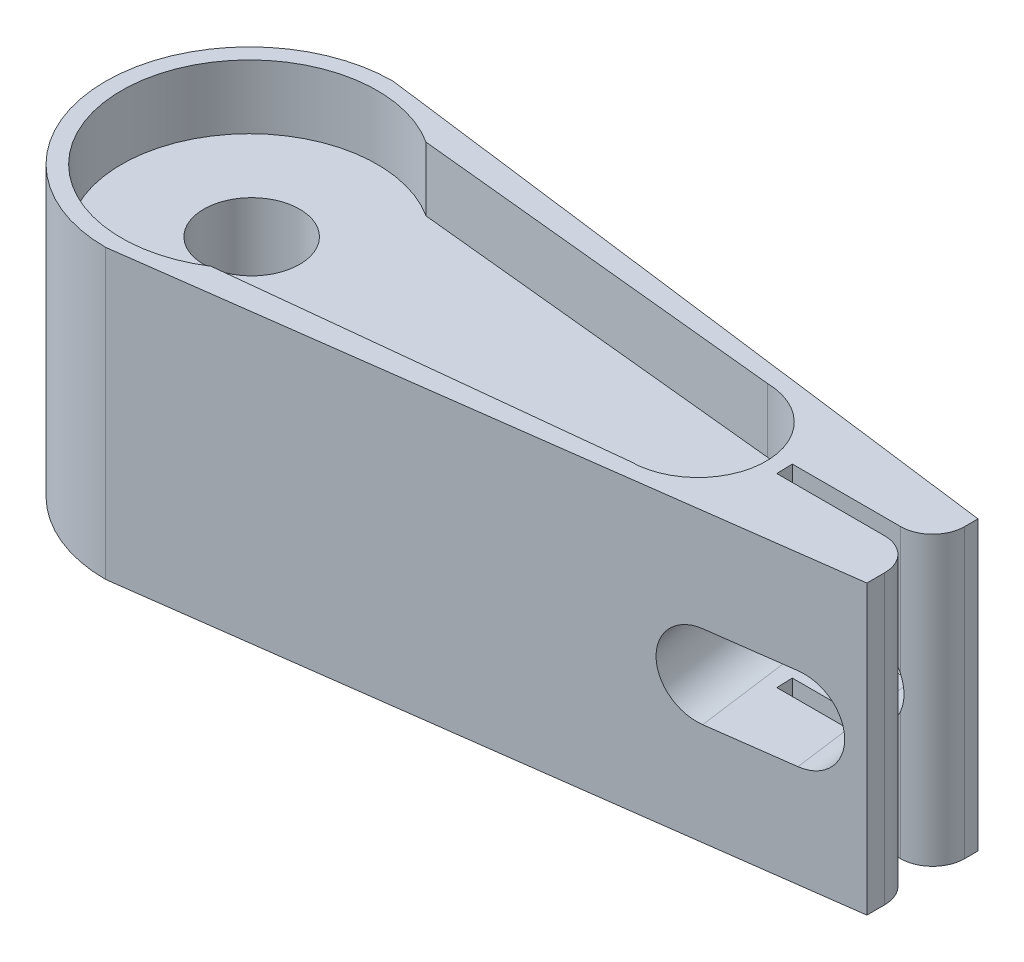
from build123d import *

# Parameters (mm, degrees)
SKETCH2_R           = 1.5
BOSS_EXTRUDE1_DEPTH = 7
BOSS_EXTRUDE2_DEPTH = 9
FILLET3_R           = 1
CUT_EXTRUDE1_DEPTH  = 34.304342473


with BuildPart() as part:
    # Sketch2 → Boss-Extrude1 (new body)
    with BuildSketch(Plane(origin=(0, 0, 0), x_dir=(1, 0, 0), z_dir=(0, 1, 0))):
        with BuildLine():
            Line((-12.939762178, 2.094266176), (-24.821781773, 3.29179515))
            ThreePointArc((-24.821781773, 3.29179515), (-30.987291256, -0.071668068), (-24.821747911, -3.435069212))
            Line((-24.821747911, -3.435069212), (-12.987160246, -2.166440487))
            ThreePointArc((-12.987160246, -2.166440487), (-10.8566751, -0.059524017), (-12.939762178, 2.094266176))
        make_face()
        with Locations((-26.987114413, 0)):
            Circle(SKETCH2_R, mode=Mode.SUBTRACT)
    extrude(amount=BOSS_EXTRUDE1_DEPTH)

    # Sketch2_3 → Boss-Extrude2 (add)
    with BuildSketch(Plane(origin=(0, 0, 0), x_dir=(1, 0, 0), z_dir=(0, 1, 0))):
        with BuildLine():
            Line((-5.980021524, -1.757335699), (-5.980297938, -0.2))
            Line((-5.980297938, -0.2), (-10.355629468, -0.2))
            Line((-10.355629468, -0.2), (-10.371987074, 0.3))
            Line((-10.371987074, 0.3), (-5.980159731, 0.3))
            Line((-5.980159731, 0.3), (-5.980159731, 1.71899167))
            Line((-5.980159731, 1.71899167), (-26.987114411, 4.428185187))
            ThreePointArc((-26.987114411, 4.428185187), (-31.48694753, -0.071647931), (-26.987114411, -4.57148105))
            Line((-26.987114411, -4.57148105), (-5.980021524, -1.757335699))
        make_face()
        with BuildLine():
            Line((-12.987160246, -2.166440487), (-24.821747911, -3.435069212))
            ThreePointArc((-24.821747911, -3.435069212), (-30.987291256, -0.071668068), (-24.821781773, 3.29179515))
            Line((-24.821781773, 3.29179515), (-12.939762178, 2.094266176))
            ThreePointArc((-12.939762178, 2.094266176), (-10.8566751, -0.059524017), (-12.987160246, -2.166440487))
        make_face(mode=Mode.SUBTRACT)
    extrude(amount=BOSS_EXTRUDE2_DEPTH)

    # Fillet3
    fillet3_edges = [part.edges().sort_by_distance(p)[0] for p in [
        (-5.980297938, 4.5, 0.2),
        (-5.980159731, 4.5, -0.3),
    ]]
    fillet(fillet3_edges, radius=FILLET3_R)

    # Sketch3 → Cut-Extrude1 (cut, through all)
    with BuildSketch(Plane(origin=(0.125841463, 0, 0.939384066), x_dir=(0.9911461251188364, 0, -0.13277559512921042), z_dir=(0.13277559512921042, 0, 0.9911461251188365))):
        with BuildLine():
            Line((-8.079177289, 3.2), (-10.730603596, 3.2))
            ThreePointArc((-10.730603596, 3.2), (-12.030603596, 4.5), (-10.730603596, 5.8))
            Line((-10.730603596, 5.8), (-8.079177289, 5.8))
            ThreePointArc((-8.079177289, 5.8), (-6.779177289, 4.5), (-8.079177289, 3.2))
        make_face()
    extrude(amount=-CUT_EXTRUDE1_DEPTH, mode=Mode.SUBTRACT)


solid = part.part
